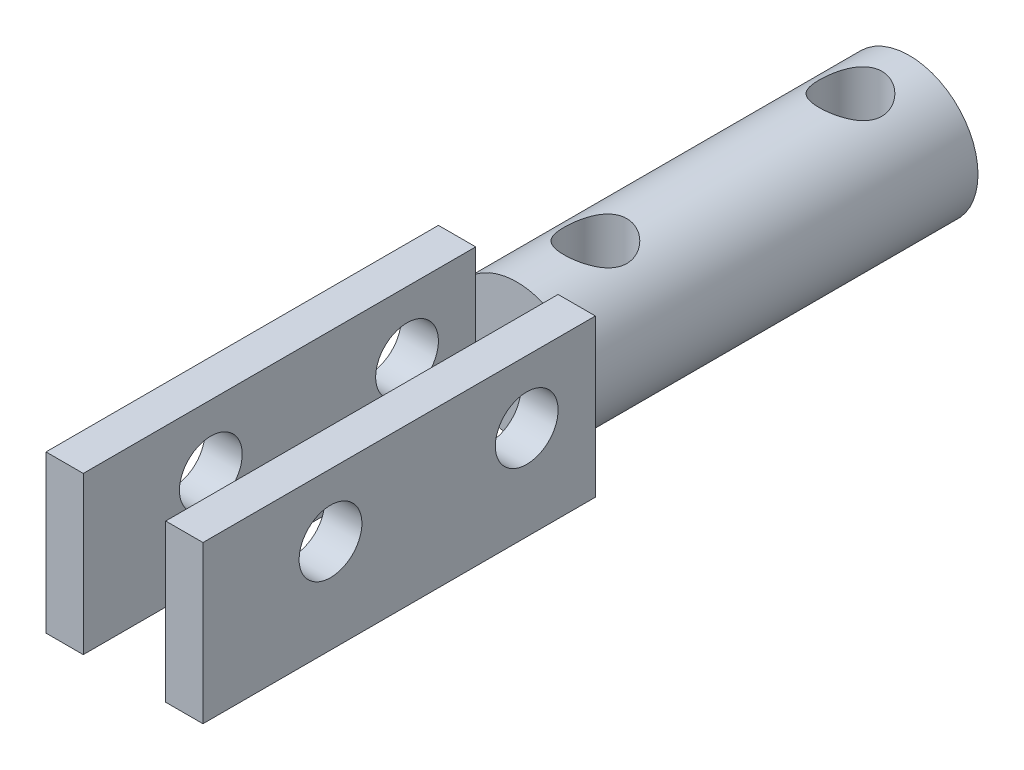
from build123d import *

# Parameters (mm, degrees)
SKETCH1_R               = 3.5
BOSS_EXTRUDE1_DEPTH     = 20
SKETCH2_R               = 1.6
CUT_EXTRUDE1_DEPTH      = 4.5
CUT_EXTRUDE1_DEPTH_BACK = 4.5
SKETCH3_W               = 8
SKETCH3_H               = 8
BOSS_EXTRUDE2_DEPTH     = 20
SKETCH4_W               = 4.2
SKETCH4_H               = 8
CUT_EXTRUDE2_DEPTH      = 20
SKETCH5_R               = 1.6
CUT_EXTRUDE3_DEPTH      = 9


with BuildPart() as part:
    # Sketch1 → Boss-Extrude1 (new body)
    with BuildSketch(Plane.XY):
        Circle(SKETCH1_R)
    extrude(amount=BOSS_EXTRUDE1_DEPTH)

    # Sketch2 → Cut-Extrude1 (cut, two sides)
    with BuildSketch(Plane(origin=(0, 0, 0), x_dir=(1, 0, 0), z_dir=(0, 1, 0))) as cut_extrude1_sk:
        with Locations((0, -3)):
            Circle(SKETCH2_R)
        with Locations((0, -16)):
            Circle(SKETCH2_R)
    extrude(amount=CUT_EXTRUDE1_DEPTH, mode=Mode.SUBTRACT)
    extrude(cut_extrude1_sk.sketch, amount=-CUT_EXTRUDE1_DEPTH_BACK, mode=Mode.SUBTRACT)

    # Sketch3 → Boss-Extrude2 (add)
    with BuildSketch(Plane.XY.offset(20)):
        Rectangle(SKETCH3_W, SKETCH3_H)
    extrude(amount=BOSS_EXTRUDE2_DEPTH)

    # Sketch4 → Cut-Extrude2 (cut)
    with BuildSketch(Plane.XY.offset(40)):
        Rectangle(SKETCH4_W, SKETCH4_H)
    extrude(amount=-CUT_EXTRUDE2_DEPTH, mode=Mode.SUBTRACT)

    # Sketch5 → Cut-Extrude3 (cut, through all)
    with BuildSketch(Plane.ZY.offset(4)):
        with Locations((33.5, 0.8)):
            Circle(SKETCH5_R)
        with Locations((23.5, 0.8)):
            Circle(SKETCH5_R)
    extrude(amount=-CUT_EXTRUDE3_DEPTH, mode=Mode.SUBTRACT)


solid = part.part
